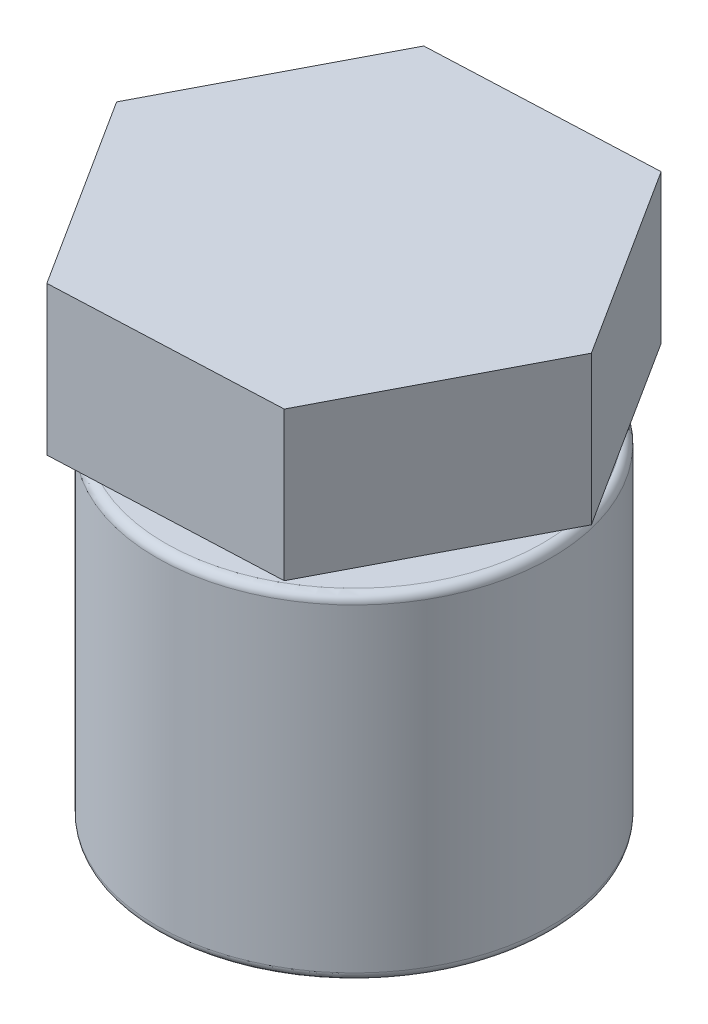
from build123d import *

# Parameters (mm, degrees)
FILLET1_R           = 2
BOSS_EXTRUDE1_DEPTH = 35


with BuildPart() as part:
    # Sketch1 → Revolve1 (revolve)
    with BuildSketch(Plane.XY):
        Polygon((0, 51.309168584), (9.365959345, 51.309168584), (9.365959345, 43.16485611), (14.252546829, 43.16485611), (14.252546829, 29.943316963), (14.897026355, 29.943316963), (14.897026355, 28.912309281), (14.252546829, 28.912309281), (14.252546829, 22.804074926), (46.422581099, 22.804074926), (46.422581099, -56.195756068), (0, -56.195756068), (0, -43.979287357), (42.350424863, -43.979287357), (42.350424863, 17.510271818), (0, 17.510271818), align=None)
    revolve(axis=Axis((0, 17.510271818, 0), (0, 1, 0)))

    # Fillet1
    fillet1_edges = [part.edges().sort_by_distance(p)[0] for p in [
        (-46.422581099, -56.195756068, 0),
        (-46.422581099, 22.804074926, 0),
    ]]
    fillet(fillet1_edges, radius=FILLET1_R)


with BuildPart() as body_2:
    # Sketch2 → Boss-Extrude1 (new body)
    with BuildSketch(Plane(origin=(0, 29.943316963, 0), x_dir=(1, 0, 0), z_dir=(0, 1, 0))):
        Polygon((28.790711038, -45.216180797), (53.553716751, 2.325396753), (24.763005713, 47.54157755), (-28.790711038, 45.216180797), (-53.553716751, -2.325396753), (-24.763005713, -47.54157755), align=None)
    extrude(amount=BOSS_EXTRUDE1_DEPTH)

    # Sketch1_2 → Cut-Revolve1 (revolve, cut)
    with BuildSketch(Plane.XY):
        Polygon((0, 51.309168584), (9.365959345, 51.309168584), (9.365959345, 43.16485611), (14.252546829, 43.16485611), (14.252546829, 29.943316963), (14.897026355, 29.943316963), (14.897026355, 28.912309281), (14.252546829, 28.912309281), (14.252546829, 22.804074926), (46.422581099, 22.804074926), (46.422581099, -56.195756068), (0, -56.195756068), (0, -43.979287357), (42.350424863, -43.979287357), (42.350424863, 17.510271818), (0, 17.510271818), align=None)
    revolve(axis=Axis((0, 17.510271818, 0), (0, 1, 0)), mode=Mode.SUBTRACT)


solid = Compound([part.part, body_2.part])
